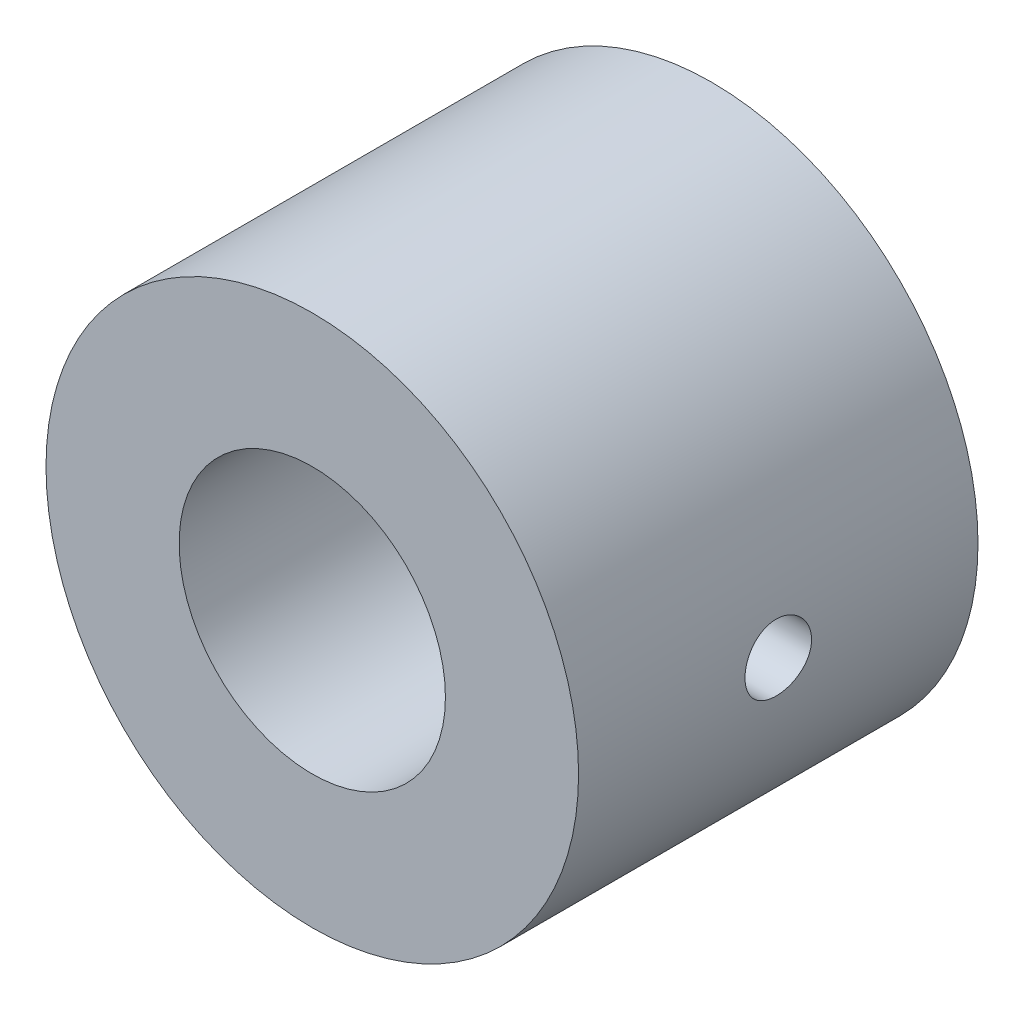
from build123d import *

# Parameters (mm, degrees)
ESQUISSE1_R           = 10
ESQUISSE1_R_2         = 5
BOSS_EXTRU_1_DEPTH    = 15
TROU_TARAUD_M31_D     = 2.5
TROU_TARAUD_M31_DEPTH = 8.5
TROU_TARAUD_M31_TIP   = 0.751075774
TROU_TARAUD_M32_D     = 2.5
TROU_TARAUD_M32_DEPTH = 8.5
TROU_TARAUD_M32_TIP   = 0.751075774


with BuildPart() as part:
    # Esquisse1 → Boss.-Extru.1 (new body)
    with BuildSketch(Plane.XY):
        Circle(ESQUISSE1_R)
        Circle(ESQUISSE1_R_2, mode=Mode.SUBTRACT)
    extrude(amount=BOSS_EXTRU_1_DEPTH)

    # Trou taraudé M31
    with Locations(Plane(origin=(10, 0, 0), x_dir=(0, 0, -1), z_dir=(1, 0, 0))):
        with Locations((-7.5, 0)):
            Hole(TROU_TARAUD_M31_D / 2, depth=TROU_TARAUD_M31_DEPTH)
            with Locations((0, 0, -(TROU_TARAUD_M31_DEPTH + TROU_TARAUD_M31_TIP / 2))):  # 118° drill point
                Cone(0, TROU_TARAUD_M31_D / 2, TROU_TARAUD_M31_TIP, mode=Mode.SUBTRACT)

    # Trou taraudé M32
    with Locations(Plane(origin=(-10, 0, 0), x_dir=(0, 0, -1), z_dir=(-1, 0, 0))):
        with Locations((-7.5, 0)):
            Hole(TROU_TARAUD_M32_D / 2, depth=TROU_TARAUD_M32_DEPTH)
            with Locations((0, 0, -(TROU_TARAUD_M32_DEPTH + TROU_TARAUD_M32_TIP / 2))):  # 118° drill point
                Cone(0, TROU_TARAUD_M32_D / 2, TROU_TARAUD_M32_TIP, mode=Mode.SUBTRACT)


solid = part.part
